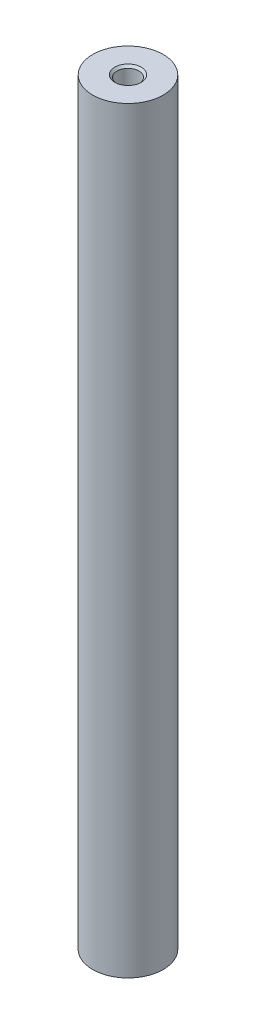
from build123d import *

# Parameters (mm, degrees)
SKETCH1_R           = 8
BOSS_EXTRUDE1_DEPTH = 172
SKETCH2_R           = 2.5
CUT_EXTRUDE1_DEPTH  = 15
CHAMFER1_SIZE       = 0.5


with BuildPart() as part:
    # Sketch1 → Boss-Extrude1 (new body)
    with BuildSketch(Plane(origin=(0, 0, 0), x_dir=(1, 0, 0), z_dir=(0, 1, 0))):
        Circle(SKETCH1_R)
    extrude(amount=BOSS_EXTRUDE1_DEPTH)

    # Sketch2 → Cut-Extrude1 (cut)
    with BuildSketch(Plane.XZ):
        Circle(SKETCH2_R)
    cut_extrude1 = extrude(amount=-CUT_EXTRUDE1_DEPTH, mode=Mode.SUBTRACT)

    # Mirror1: Cut-Extrude1 across plane
    add(cut_extrude1.mirror(Plane.ZX.offset(86)), mode=Mode.SUBTRACT)

    # Chamfer1
    chamfer1_edges = [part.edges().sort_by_distance(p)[0] for p in [
        (-2.5, 0, 0),
        (-2.5, 172, 0),
    ]]
    chamfer(chamfer1_edges, length=CHAMFER1_SIZE)


solid = part.part
